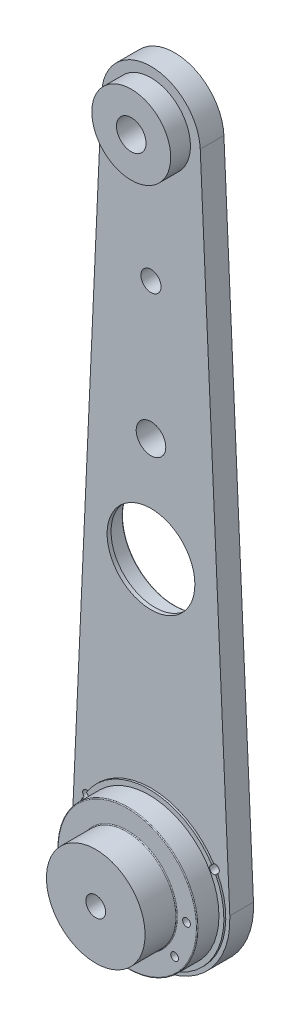
from build123d import *

# Parameters (mm, degrees)
SKETCH1_R               = 4.7625
BOSS_EXTRUDE1_DEPTH     = 3.81
SKETCH2_R               = 22.5
BOSS_EXTRUDE2_DEPTH     = 7.62
SKETCH3_R               = 24.08993992
BOSS_EXTRUDE3_DEPTH     = 0.62
SKETCH4_R               = 16.66875
SKETCH4_R_2             = 4.7625
CUT_EXTRUDE1_DEPTH      = 8.62
CUT_EXTRUDE1_DEPTH_BACK = 8.62
SKETCH6_R               = 16.66875
SKETCH6_R_2             = 14.12875
BOSS_EXTRUDE4_DEPTH     = 1.27
CUT_EXTRUDE2_DEPTH      = 2.54
SKETCH8_R               = 0.95
CUT_EXTRUDE3_DEPTH      = 13.7
SKETCH9_R               = 12.7
SKETCH9_R_2             = 4.7625
BOSS_EXTRUDE5_DEPTH     = 6.35
SKETCH10_R              = 15.875
BOSS_EXTRUDE6_DEPTH     = 10.16
SKETCH11_R              = 1.25
CUT_EXTRUDE4_DEPTH      = 1
CUT_EXTRUDE4_DEPTH_BACK = 26.4
SKETCH12_R              = 3.2385
CUT_EXTRUDE5_DEPTH      = 18.78
CUT_EXTRUDE5_DEPTH_BACK = 8.62
SKETCH14_R              = 3.175
CUT_EXTRUDE6_DEPTH      = 23.86
SKETCH15_R              = 6.35
CUT_EXTRUDE7_DEPTH      = 7.62
FILLET1_R               = 0.254


with BuildPart() as part:
    # Sketch1 → Boss-Extrude1 (new body, symmetric)
    with BuildSketch(Plane.XY):
        with BuildLine():
            Line((25.373713394, 1.155278592), (15.858570871, 210.139069198))
            ThreePointArc((15.858570871, 210.139069198), (0, 225.292020078), (-15.858570871, 210.139069198))
            Line((-15.858570871, 210.139069198), (-25.373713394, 1.155278592))
            ThreePointArc((-25.373713394, 1.155278592), (0, -25.4), (25.373713394, 1.155278592))
        make_face()
        with Locations((0, 209.417020078)):
            Circle(SKETCH1_R, mode=Mode.SUBTRACT)
    extrude(amount=BOSS_EXTRUDE1_DEPTH, both=True)

    # Sketch2 → Boss-Extrude2 (add)
    with BuildSketch(Plane.XY.offset(3.81)):
        Circle(SKETCH2_R)
    extrude(amount=BOSS_EXTRUDE2_DEPTH)

    # Sketch3 → Boss-Extrude3 (add)
    with BuildSketch(Plane.XY.offset(3.81)):
        Circle(SKETCH3_R)
    extrude(amount=BOSS_EXTRUDE3_DEPTH)

    # Sketch4 → Cut-Extrude1 (cut, two sides)
    with BuildSketch(Plane.XY.offset(3.81)) as cut_extrude1_sk:
        with Locations((0, 87.91702)):
            Circle(SKETCH4_R)
        with Locations((0, 121.500000078)):
            Circle(SKETCH4_R_2)
    extrude(amount=CUT_EXTRUDE1_DEPTH, mode=Mode.SUBTRACT)
    extrude(cut_extrude1_sk.sketch, amount=-CUT_EXTRUDE1_DEPTH_BACK, mode=Mode.SUBTRACT)

    # Sketch6 → Boss-Extrude4 (add)
    with BuildSketch(Plane.XY.offset(3.81)):
        with Locations((0, 87.91702)):
            Circle(SKETCH6_R)
        with Locations((0, 87.91702)):
            Circle(SKETCH6_R_2, mode=Mode.SUBTRACT)
    extrude(amount=-BOSS_EXTRUDE4_DEPTH)

    # Sketch7 → Cut-Extrude2 (cut)
    with BuildSketch(Plane(origin=(0, 0, -3.81), x_dir=(-1, 0, 0), z_dir=(0, 0, -1))):
        with BuildLine():
            Line((-11.79375, -8.35625), (-11.79375, 8.35625))
            Line((-11.79375, 8.35625), (11.79375, 8.35625))
            Line((11.79375, 8.35625), (11.79375, -8.35625))
            Line((11.79375, -8.35625), (11.79375, -22.495943211))
            ThreePointArc((11.79375, -22.495943211), (0, -25.4), (-11.79375, -22.495943211))
            Line((-11.79375, -22.495943211), (-11.79375, -8.35625))
        make_face()
    extrude(amount=-CUT_EXTRUDE2_DEPTH, mode=Mode.SUBTRACT)

    # Sketch8 → Cut-Extrude3 (cut, through all)
    with BuildSketch(Plane(origin=(0, 0, -1.27), x_dir=(-1, 0, 0), z_dir=(0, 0, -1))):
        with Locations((9, -5.5625)):
            Circle(SKETCH8_R)
        with Locations((-9, -5.5625)):
            Circle(SKETCH8_R)
        with Locations((-9, 5.5625)):
            Circle(SKETCH8_R)
        with Locations((9, 5.5625)):
            Circle(SKETCH8_R)
    extrude(amount=-CUT_EXTRUDE3_DEPTH, mode=Mode.SUBTRACT)

    # Sketch9 → Boss-Extrude5 (add)
    with BuildSketch(Plane.XY.offset(3.81)):
        with Locations((0, 209.417020078)):
            Circle(SKETCH9_R)
        with Locations((0, 209.417020078)):
            Circle(SKETCH9_R_2, mode=Mode.SUBTRACT)
    extrude(amount=BOSS_EXTRUDE5_DEPTH)

    # Sketch10 → Boss-Extrude6 (add)
    with BuildSketch(Plane.XY.offset(11.43)):
        Circle(SKETCH10_R)
    extrude(amount=BOSS_EXTRUDE6_DEPTH)

    # Sketch11 → Cut-Extrude4 (cut, two sides)
    with BuildSketch(Plane(origin=(0, 0, -3.81), x_dir=(-1, 0, 0), z_dir=(0, 0, -1))) as cut_extrude4_sk:
        with Locations((-20.743073922, 11.982962866)):
            Circle(SKETCH11_R)
        with Locations((-19.061789704, 0)):
            Circle(SKETCH11_R)
        with Locations((-15.221171432, -11.474657597)):
            Circle(SKETCH11_R)
        with Locations((15.221171432, -11.474657597)):
            Circle(SKETCH11_R)
        with Locations((19.061789704, 0)):
            Circle(SKETCH11_R)
        with Locations((20.743073922, 11.982962866)):
            Circle(SKETCH11_R)
    extrude(amount=CUT_EXTRUDE4_DEPTH, mode=Mode.SUBTRACT)
    extrude(cut_extrude4_sk.sketch, amount=-CUT_EXTRUDE4_DEPTH_BACK, mode=Mode.SUBTRACT)

    # Sketch12 → Cut-Extrude5 (cut, two sides)
    with BuildSketch(Plane.XY.offset(3.81)) as cut_extrude5_sk:
        with Locations((0, 165.458510078)):
            Circle(SKETCH12_R)
    extrude(amount=CUT_EXTRUDE5_DEPTH, mode=Mode.SUBTRACT)
    extrude(cut_extrude5_sk.sketch, amount=-CUT_EXTRUDE5_DEPTH_BACK, mode=Mode.SUBTRACT)

    # Sketch14 → Cut-Extrude6 (cut, through all)
    with BuildSketch(Plane(origin=(0, 0, -1.27), x_dir=(-1, 0, 0), z_dir=(0, 0, -1))):
        Circle(SKETCH14_R)
    extrude(amount=-CUT_EXTRUDE6_DEPTH, mode=Mode.SUBTRACT)

    # Sketch15 → Cut-Extrude7 (cut)
    with BuildSketch(Plane(origin=(0, 0, -1.27), x_dir=(-1, 0, 0), z_dir=(0, 0, -1))):
        Circle(SKETCH15_R)
    extrude(amount=-CUT_EXTRUDE7_DEPTH, mode=Mode.SUBTRACT)

    # Fillet1
    fillet1_edges = [part.edges().sort_by_distance(p)[0] for p in [
        (-22.5, 0, 11.43),
        (-16.66875, 87.91702, -3.81),
        (-16.66875, 87.91702, 2.54),
        (-15.875, 0, 11.43),
    ]]
    fillet(fillet1_edges, radius=FILLET1_R)


solid = part.part
